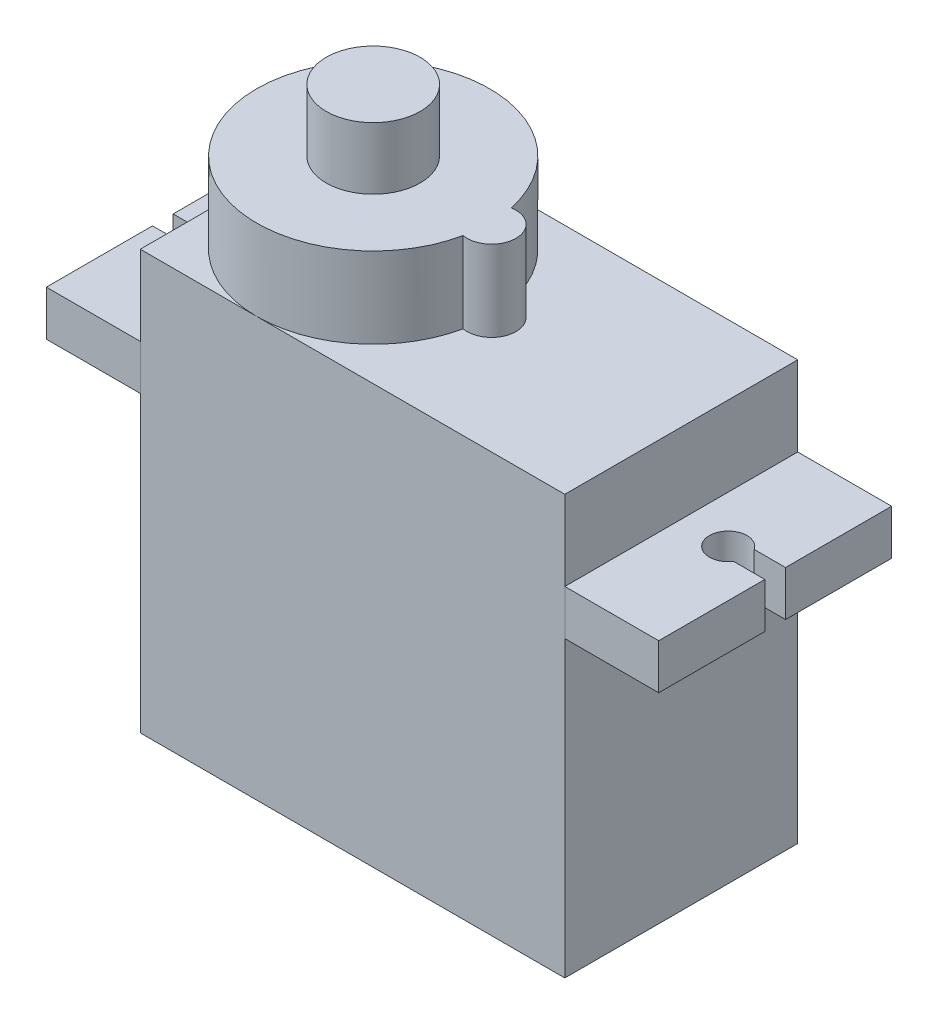
from build123d import *

# Parameters (mm, degrees)
SKETCH1_W             = 22.6
SKETCH1_H             = 12.4
BOSS_EXTRUDE1_DEPTH   = 22.3
SKETCH2_W             = 12.4
SKETCH2_H             = 2.4
BOSS_EXTRUDE2_DEPTH   = 5
SKETCH3_W             = 12.4
SKETCH3_H             = 2.4
BOSS_EXTRUDE3_DEPTH   = 5
CUT_EXTRUDE1_DEPTH    = 2.4
CUT_EXTRUDE2_DEPTH    = 2.4
BOSS_EXTRUDE4_DEPTH   = 4.3
SKETCH7_R             = 2.5
BOSS_EXTRUDE5_DEPTH   = 3.3
SKETCH8_R             = 0.6
BOSS_EXTRUDE7_DEPTH   = 2.3
BOSS_EXTRUDE7_2_DEPTH = 2.3
BOSS_EXTRUDE7_3_DEPTH = 2.3


with BuildPart() as part:
    # Sketch1 → Boss-Extrude1 (new body)
    with BuildSketch(Plane(origin=(0, 0, 0), x_dir=(1, 0, 0), z_dir=(0, 1, 0))):
        Rectangle(SKETCH1_W, SKETCH1_H)
    extrude(amount=BOSS_EXTRUDE1_DEPTH)

    # Sketch6 → Boss-Extrude4 (add)
    with BuildSketch(Plane(origin=(0, 22.3, 0), x_dir=(1, 0, 0), z_dir=(0, 1, 0))):
        with BuildLine():
            ThreePointArc((0.966666667, -1.278888406), (2.5, 0), (0.966666667, 1.278888406))
            ThreePointArc((0.966666667, 1.278888406), (-11.3, 0), (0.966666667, -1.278888406))
        make_face()
    extrude(amount=BOSS_EXTRUDE4_DEPTH)

    # Sketch7 → Boss-Extrude5 (add)
    with BuildSketch(Plane(origin=(0, 26.6, 0), x_dir=(1, 0, 0), z_dir=(0, 1, 0))):
        with Locations((-5.1, 0)):
            Circle(SKETCH7_R)
    extrude(amount=BOSS_EXTRUDE5_DEPTH)


with BuildPart() as body_2:
    # Sketch2 → Boss-Extrude2 (new body)
    with BuildSketch(Plane(origin=(11.3, 0, 0), x_dir=(0, 0, -1), z_dir=(1, 0, 0))):
        with Locations((0, 16.85)):
            Rectangle(SKETCH2_W, SKETCH2_H)
    extrude(amount=BOSS_EXTRUDE2_DEPTH)

    # Sketch5 → Cut-Extrude2 (cut)
    with BuildSketch(Plane(origin=(0, 18.05, 0), x_dir=(1, 0, 0), z_dir=(0, 1, 0))):
        with BuildLine():
            Line((14.635164654, 0.55), (16.3, 0.55))
            Line((16.3, 0.55), (16.3, -0.55))
            Line((16.3, -0.55), (14.635164654, -0.55))
            ThreePointArc((14.635164654, -0.55), (12.8, 0), (14.635164654, 0.55))
        make_face()
    extrude(amount=-CUT_EXTRUDE2_DEPTH, mode=Mode.SUBTRACT)


with BuildPart() as body_3:
    # Sketch3 → Boss-Extrude3 (new body)
    with BuildSketch(Plane.ZY.offset(11.3)):
        with Locations((0, 16.85)):
            Rectangle(SKETCH3_W, SKETCH3_H)
    extrude(amount=BOSS_EXTRUDE3_DEPTH)

    # Sketch4 → Cut-Extrude1 (cut)
    with BuildSketch(Plane(origin=(0, 18.05, 0), x_dir=(1, 0, 0), z_dir=(0, 1, 0))):
        with BuildLine():
            Line((-16.3, 0.55), (-14.635164654, 0.55))
            ThreePointArc((-14.635164654, 0.55), (-12.8, 0), (-14.635164654, -0.55))
            Line((-14.635164654, -0.55), (-16.3, -0.55))
            Line((-16.3, -0.55), (-16.3, 0.55))
        make_face()
        with BuildLine():
            Line((16.3, -0.55), (14.635164654, -0.55))
            ThreePointArc((14.635164654, -0.55), (12.8, 0), (14.635164654, 0.55))
            Line((14.635164654, 0.55), (16.3, 0.55))
            Line((16.3, 0.55), (16.3, -0.55))
        make_face()
    extrude(amount=-CUT_EXTRUDE1_DEPTH, mode=Mode.SUBTRACT)


with BuildPart() as body_4:
    # Sketch8 → Boss-Extrude7 (new body)
    with BuildSketch(Plane.ZY.offset(11.3)):
        with Locations((0, 4.5)):
            Circle(SKETCH8_R)
    extrude(amount=BOSS_EXTRUDE7_DEPTH)


with BuildPart() as body_5:
    # Sketch8 → Boss-Extrude7 2 (new body)
    with BuildSketch(Plane.ZY.offset(11.3)):
        with Locations((-1.2, 4.5)):
            Circle(SKETCH8_R)
    extrude(amount=BOSS_EXTRUDE7_2_DEPTH)


with BuildPart() as body_6:
    # Sketch8 → Boss-Extrude7 3 (new body)
    with BuildSketch(Plane.ZY.offset(11.3)):
        with Locations((1.2, 4.5)):
            Circle(SKETCH8_R)
    extrude(amount=BOSS_EXTRUDE7_3_DEPTH)


solid = Compound([part.part, body_2.part, body_3.part, body_4.part, body_5.part, body_6.part])
